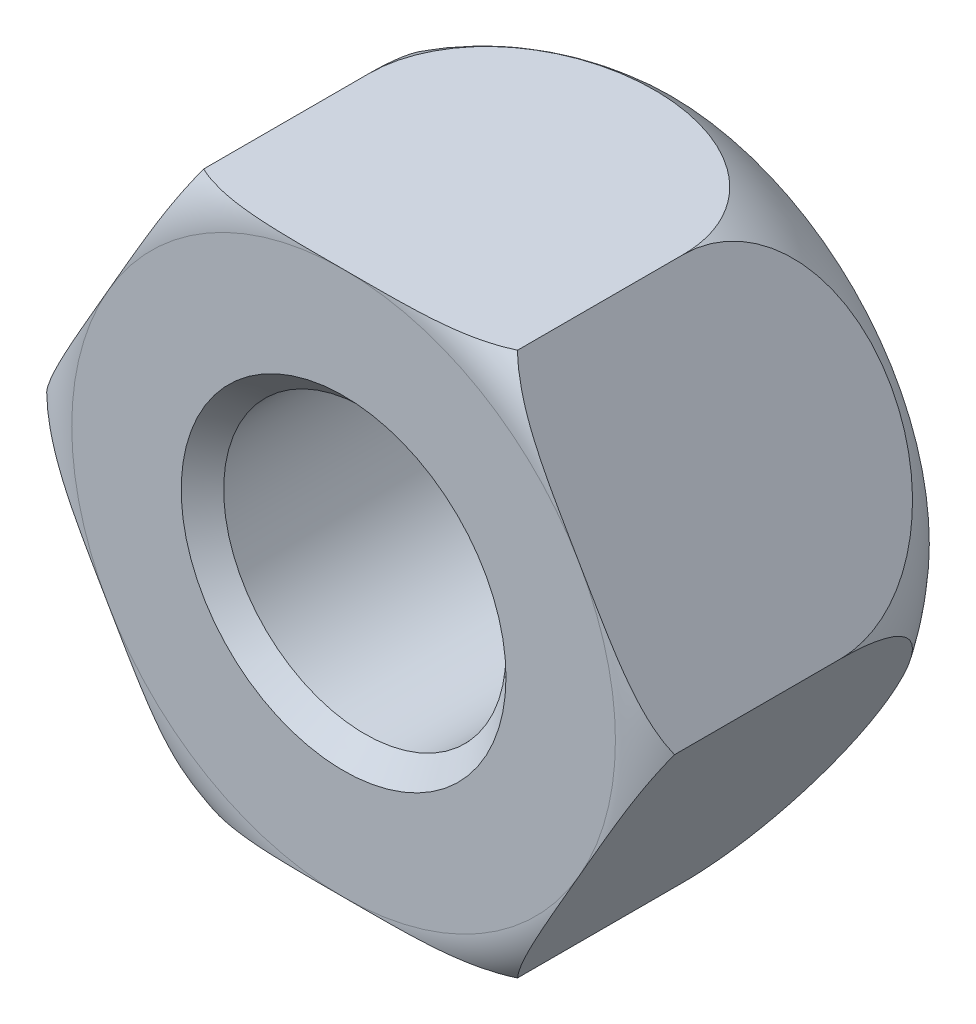
from build123d import *

# Parameters (mm, degrees)
SKETCH1_R           = 3.3235
BOSS_EXTRUDE1_DEPTH = 7.7
CHAMFER1_SIZE       = 0.5


with BuildPart() as part:
    # Sketch1 → Boss-Extrude1 (new body)
    with BuildSketch(Plane.XY):
        Polygon((3.695041723, 6.4), (-3.695041723, 6.4), (-7.390083446, 0), (-3.695041723, -6.4), (3.695041723, -6.4), (7.390083446, 0), align=None)
        Circle(SKETCH1_R, mode=Mode.SUBTRACT)
    extrude(amount=-BOSS_EXTRUDE1_DEPTH)

    # Sketch2 → Cut-Revolve1 (revolve, cut)
    with BuildSketch(Plane(origin=(0, 0, 0), x_dir=(1, 0, 0), z_dir=(0, 1, 0))):
        with BuildLine():
            Line((-7.390083446, 7.7), (-7.390083446, 4.3))
            ThreePointArc((-7.390083446, 4.3), (-7.05400145, 6.120027472), (-6.090083446, 7.7))
            Line((-6.090083446, 7.7), (-7.390083446, 7.7))
        make_face()
        with BuildLine():
            Line((-7.390083446, 0), (-7.390083446, 0.4))
            ThreePointArc((-7.390083446, 0.4), (-6.933916011, 0.103778026), (-6.4, 0))
            Line((-6.4, 0), (-7.390083446, 0))
        make_face()
    revolve(axis=Axis((0, 0, -88.99), (0, 0, 1)), mode=Mode.SUBTRACT)

    # Chamfer1
    chamfer1_edges = [part.edges().sort_by_distance(p)[0] for p in [
        (-3.3235, 0, -7.7),
        (-3.3235, 0, 0),
    ]]
    chamfer(chamfer1_edges, length=CHAMFER1_SIZE)


solid = part.part
